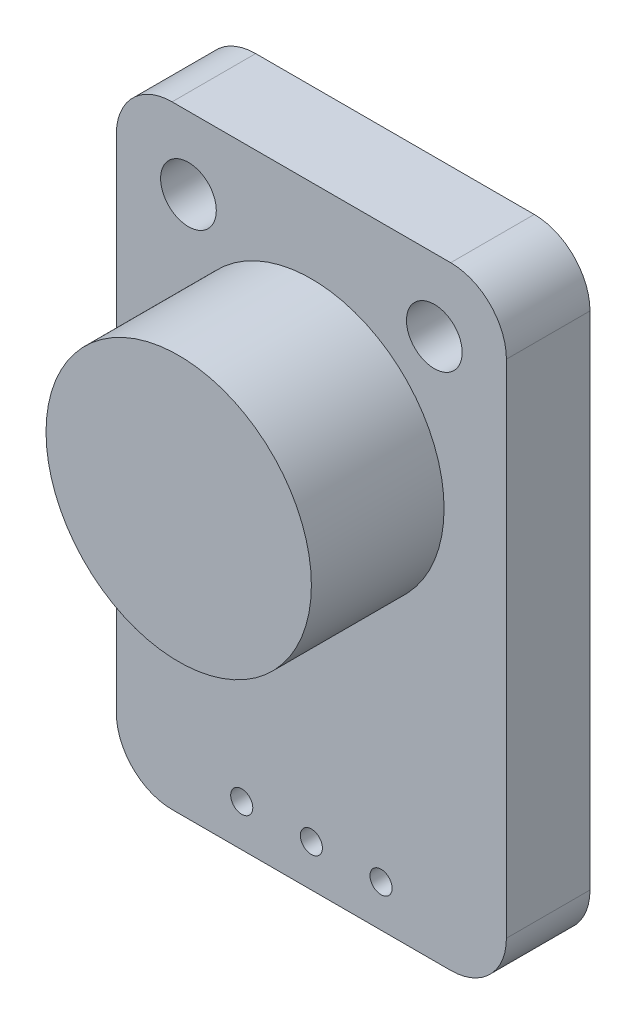
from build123d import *

# Parameters (mm, degrees)
SKETCH1_R               = 4.7625
BOSS_EXTRUDE1_DEPTH     = 4.7625
SKETCH1_3_W             = 14
SKETCH1_3_H             = 22
BOSS_EXTRUDE2_DEPTH     = 3
FILLET1_R               = 2
CUT_EXTRUDE1_DEPTH      = 17.56465552
CUT_EXTRUDE1_DEPTH_BACK = 17.56465552
SKETCH2_R               = 0.396875
SKETCH2_R_2             = 1


with BuildPart() as part:
    # Sketch1 → Boss-Extrude1 (new body)
    with BuildSketch(Plane.XY):
        Circle(SKETCH1_R)
    extrude(amount=BOSS_EXTRUDE1_DEPTH)

    # Sketch1_3 → Boss-Extrude2 (add)
    with BuildSketch(Plane.XY):
        with Locations((0, -3.2375)):
            Rectangle(SKETCH1_3_W, SKETCH1_3_H)
    extrude(amount=-BOSS_EXTRUDE2_DEPTH)

    # Fillet1
    fillet1_edges = [part.edges().sort_by_distance(p)[0] for p in [
        (-7, -14.2375, -1.5),
        (-7, 7.7625, -1.5),
        (7, -14.2375, -1.5),
        (7, 7.7625, -1.5),
    ]]
    fillet(fillet1_edges, radius=FILLET1_R)

    # Sketch2 → Cut-Extrude1 (cut, two sides: drawn at the far end of the back side and taken through both)
    with BuildSketch(Plane.XY.offset(-CUT_EXTRUDE1_DEPTH_BACK)):
        with Locations((0, -12.7375)):
            Circle(SKETCH2_R)
        with Locations((2.5, -12.7375)):
            Circle(SKETCH2_R)
        with Locations((-2.5, -12.7375)):
            Circle(SKETCH2_R)
        with Locations((-4.4125, 5.175)):
            Circle(SKETCH2_R_2)
        with Locations((4.4125, 5.175)):
            Circle(SKETCH2_R_2)
    extrude(amount=CUT_EXTRUDE1_DEPTH + CUT_EXTRUDE1_DEPTH_BACK, mode=Mode.SUBTRACT)


solid = part.part
